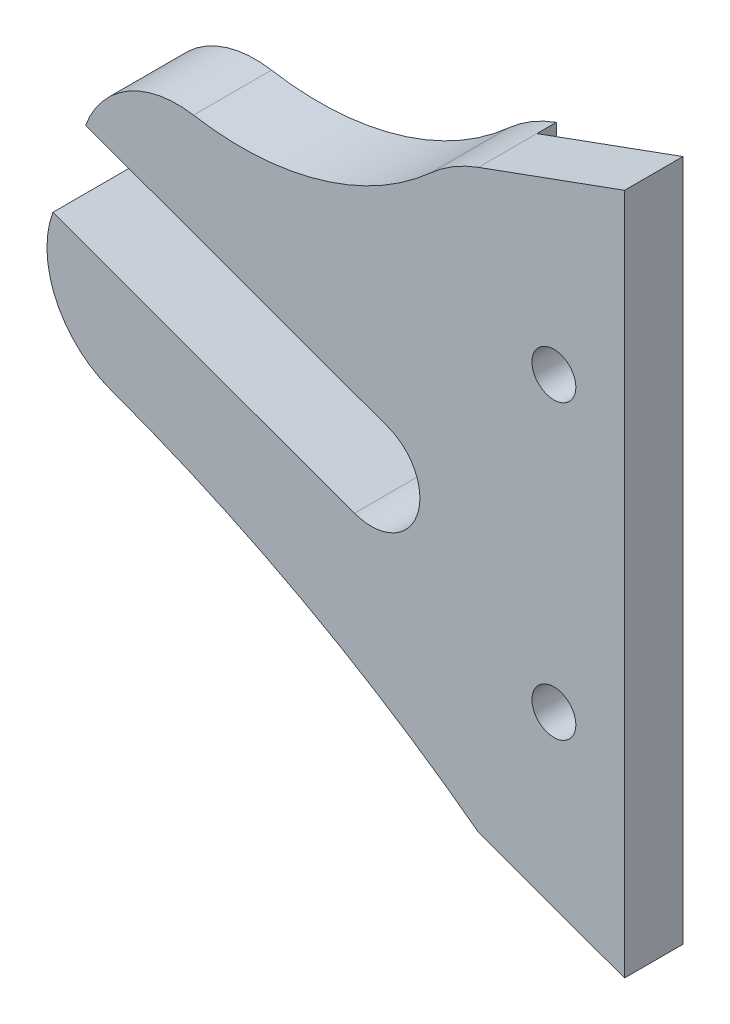
from build123d import *

# Parameters (mm, degrees)
EXTRUSION1_DEPTH = 8
ESQUISSE5_W      = 17.091778577
ESQUISSE5_H      = 76.980294062
EXTRUSION3_DEPTH = 2
ESQUISSE6_R      = 2.25
EXTRUSION4_DEPTH = 7


with BuildPart() as part:
    # Esquisse1 → Extrusion1 (new body)
    with BuildSketch(Plane.XY):
        with BuildLine():
            Line((34.346799903, -30.256527517), (34.346799903, 39.743472483))
            Line((34.346799903, 39.743472483), (19.346799903, 34.283918969))
            ThreePointArc((19.346799903, 34.283918969), (16.761888626, 33.052257025), (14.45811141, 31.351854722))
            ThreePointArc((14.45811141, 31.351854722), (3.093427207, 25.046605726), (-9.882286187, 24.309670273))
            ThreePointArc((-9.882286187, 24.309670273), (-16.583574554, 23.095028583), (-20.952955866, 17.870937546))
            Line((-20.952955866, 17.870937546), (10.05690062, 6.584272816))
            ThreePointArc((10.05690062, 6.584272816), (13.045263007, 0.175708995), (6.636699186, -2.812653392))
            Line((6.636699186, -2.812653392), (-24.3170743, 8.453598795))
            ThreePointArc((-24.3170743, 8.453598795), (-23.983225962, 0.807214745), (-18.340349525, -4.363528846))
            ThreePointArc((-18.340349525, -4.363528846), (1.25940449, -13.185565307), (19.346799903, -24.796974003))
            Line((19.346799903, -24.796974003), (34.346799903, -30.256527517))
        make_face()
    extrude(amount=EXTRUSION1_DEPTH)

    # Esquisse5 → Extrusion3 (cut)
    with BuildSketch(Plane(origin=(0, 0, 0), x_dir=(-1, 0, 0), z_dir=(0, 0, -1))):
        with Locations((-27.892689192, 3.666825014)):
            Rectangle(ESQUISSE5_W, ESQUISSE5_H)
    extrude(amount=-EXTRUSION3_DEPTH, mode=Mode.SUBTRACT)

    # Esquisse6 → Extrusion4 (cut, through all)
    with BuildSketch(Plane(origin=(0, 0, 2), x_dir=(-1, 0, 0), z_dir=(0, 0, -1))):
        with Locations((-27.096799903, 19.743472483)):
            Circle(ESQUISSE6_R)
        with Locations((-27.096799903, -10.256527517)):
            Circle(ESQUISSE6_R)
    extrude(amount=-EXTRUSION4_DEPTH, mode=Mode.SUBTRACT)


solid = part.part
